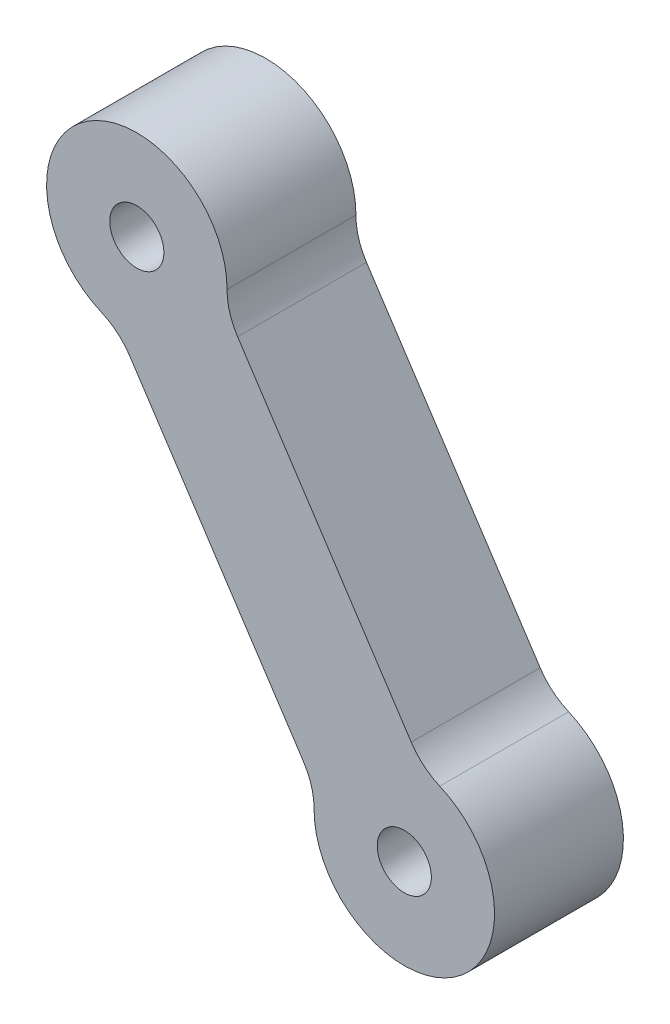
from build123d import *

# Parameters (mm, degrees)
CROQUIS1_R              = 2.1
SALIENTE_EXTRUIR1_DEPTH = 10


with BuildPart() as part:
    # Croquis1 → Saliente-Extruir1 (new body)
    with BuildSketch(Plane.XY):
        with BuildLine():
            Line((-32.290971733, 56.341666114), (-18.820923588, 35.836777273))
            ThreePointArc((-18.820923588, 35.836777273), (-18.206352607, 34.513543688), (-17.999930323, 33.069232623))
            ThreePointArc((-17.999930323, 33.069232623), (-7.156670206, 27.187460188), (-8.249030533, 39.474782348))
            ThreePointArc((-8.249030533, 39.474782348), (-9.492618022, 40.237760126), (-10.463009658, 41.327248541))
            Line((-10.463009658, 41.327248541), (-23.933057655, 61.832137156))
            ThreePointArc((-23.933057655, 61.832137156), (-24.54762873, 63.155370924), (-24.754051068, 64.59968219))
            ThreePointArc((-24.754051068, 64.59968219), (-35.597311345, 70.481454363), (-34.504950654, 58.19413222))
            ThreePointArc((-34.504950654, 58.19413222), (-33.261363284, 57.431154458), (-32.290971733, 56.341666114))
        make_face()
        with Locations((-31.753981392, 64.630914655)):
            Circle(CROQUIS1_R, mode=Mode.SUBTRACT)
        with Locations((-11, 33.038)):
            Circle(CROQUIS1_R, mode=Mode.SUBTRACT)
    extrude(amount=SALIENTE_EXTRUIR1_DEPTH)


solid = part.part
